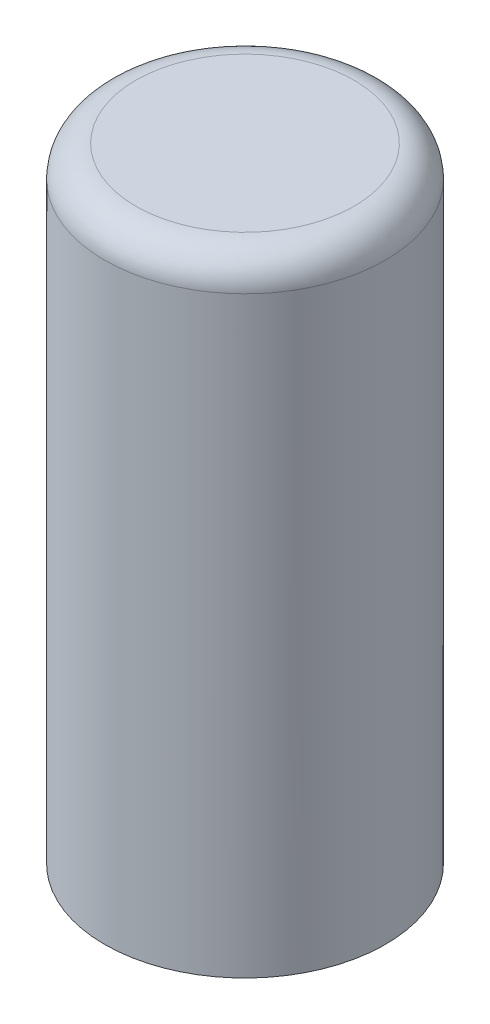
from build123d import *

# Parameters (mm, degrees)
SKETCH2_R           = 4.5
SKETCH2_R_2         = 3
BOSS_EXTRUDE1_DEPTH = 20
SKETCH2_2_R         = 3
BOSS_EXTRUDE2_DEPTH = 2
FILLET1_R           = 1


with BuildPart() as part:
    # Sketch2 → Boss-Extrude1 (new body)
    with BuildSketch(Plane(origin=(0, 0, 0), x_dir=(1, 0, 0), z_dir=(0, 1, 0))):
        Circle(SKETCH2_R)
        Circle(SKETCH2_R_2, mode=Mode.SUBTRACT)
    extrude(amount=-BOSS_EXTRUDE1_DEPTH)

    # Sketch2_2 → Boss-Extrude2 (add)
    with BuildSketch(Plane(origin=(0, 0, 0), x_dir=(1, 0, 0), z_dir=(0, 1, 0))):
        Circle(SKETCH2_2_R)
    extrude(amount=-BOSS_EXTRUDE2_DEPTH)

    # Fillet1
    fillet1_edges = [part.edges().sort_by_distance(p)[0] for p in [
        (-4.5, 0, 0),
    ]]
    fillet(fillet1_edges, radius=FILLET1_R)


solid = part.part
